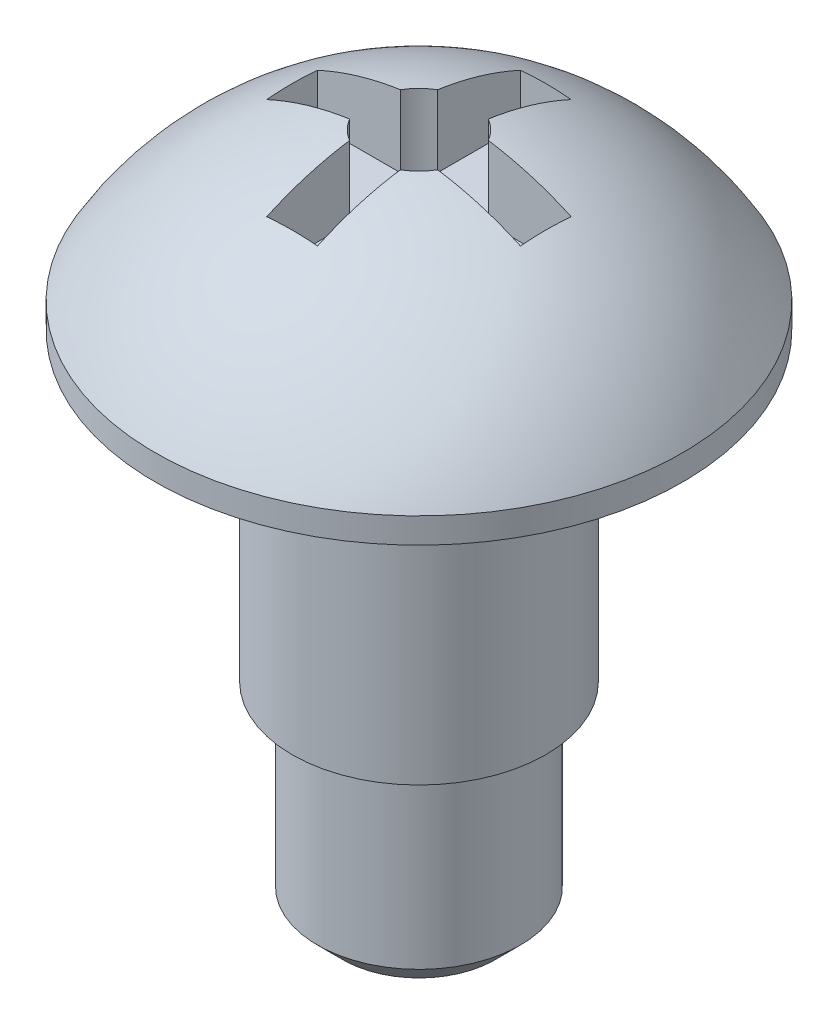
from build123d import *

# Parameters (mm, degrees)
ESQUISSE2_R             = 5.196152423
BOSS_EXTRU_1_DEPTH      = 0.5
ESQUISSE3_R             = 2.5
BOSS_EXTRU_2_DEPTH      = 6
ESQUISSE4_R             = 2
BOSS_EXTRU_3_DEPTH      = 4
CHANFREIN1_SIZE         = 0.5
ENL_V_MAT_EXTRU_2_DEPTH = 2


with BuildPart() as part:
    # Esquisse1 → Base-Révolution (revolve)
    with BuildSketch(Plane.XY):
        with BuildLine():
            Line((0, 3), (5.196152423, 3))
            ThreePointArc((5.196152423, 3), (3, 5.196152423), (0, 6))
            Line((0, 6), (0, 3))
        make_face()
    revolve(axis=Axis((0, 0, 0), (0, 1, 0)))

    # Esquisse2 → Boss.-Extru.1 (add)
    with BuildSketch(Plane.XZ.offset(-3)):
        Circle(ESQUISSE2_R)
    extrude(amount=BOSS_EXTRU_1_DEPTH)

    # Esquisse3 → Boss.-Extru.2 (add)
    with BuildSketch(Plane.XZ.offset(-2.5)):
        Circle(ESQUISSE3_R)
    extrude(amount=BOSS_EXTRU_2_DEPTH)

    # Esquisse4 → Boss.-Extru.3 (add)
    with BuildSketch(Plane.XZ.offset(3.5)):
        Circle(ESQUISSE4_R)
    extrude(amount=BOSS_EXTRU_3_DEPTH)

    # Chanfrein1
    chanfrein1_edges = [part.edges().sort_by_distance(p)[0] for p in [
        (-2, -7.5, 0),
    ]]
    chamfer(chanfrein1_edges, length=CHANFREIN1_SIZE)

    # Esquisse5 → Enlèv. mat.-Extru.2 (cut)
    with BuildSketch(Plane.XZ.offset(-6.5)):
        with BuildLine():
            Line((-0.5, -2.5), (-0.5, -0.866025404))
            ThreePointArc((-0.5, -0.866025404), (-0.707106781, -0.707106781), (-0.866025404, -0.5))
            Line((-0.866025404, -0.5), (-2.5, -0.5))
            Line((-2.5, -0.5), (-2.5, 0.5))
            Line((-2.5, 0.5), (-0.866025404, 0.5))
            ThreePointArc((-0.866025404, 0.5), (-0.707106781, 0.707106781), (-0.5, 0.866025404))
            Line((-0.5, 0.866025404), (-0.5, 2.5))
            Line((-0.5, 2.5), (0.5, 2.5))
            Line((0.5, 2.5), (0.5, 0.866025404))
            ThreePointArc((0.5, 0.866025404), (0.707106781, 0.707106781), (0.866025404, 0.5))
            Line((0.866025404, 0.5), (2.5, 0.5))
            Line((2.5, 0.5), (2.5, -0.5))
            Line((2.5, -0.5), (0.866025404, -0.5))
            ThreePointArc((0.866025404, -0.5), (0.707106781, -0.707106781), (0.5, -0.866025404))
            Line((0.5, -0.866025404), (0.5, -2.5))
            Line((0.5, -2.5), (-0.5, -2.5))
        make_face()
    extrude(amount=ENL_V_MAT_EXTRU_2_DEPTH, mode=Mode.SUBTRACT)


solid = part.part
